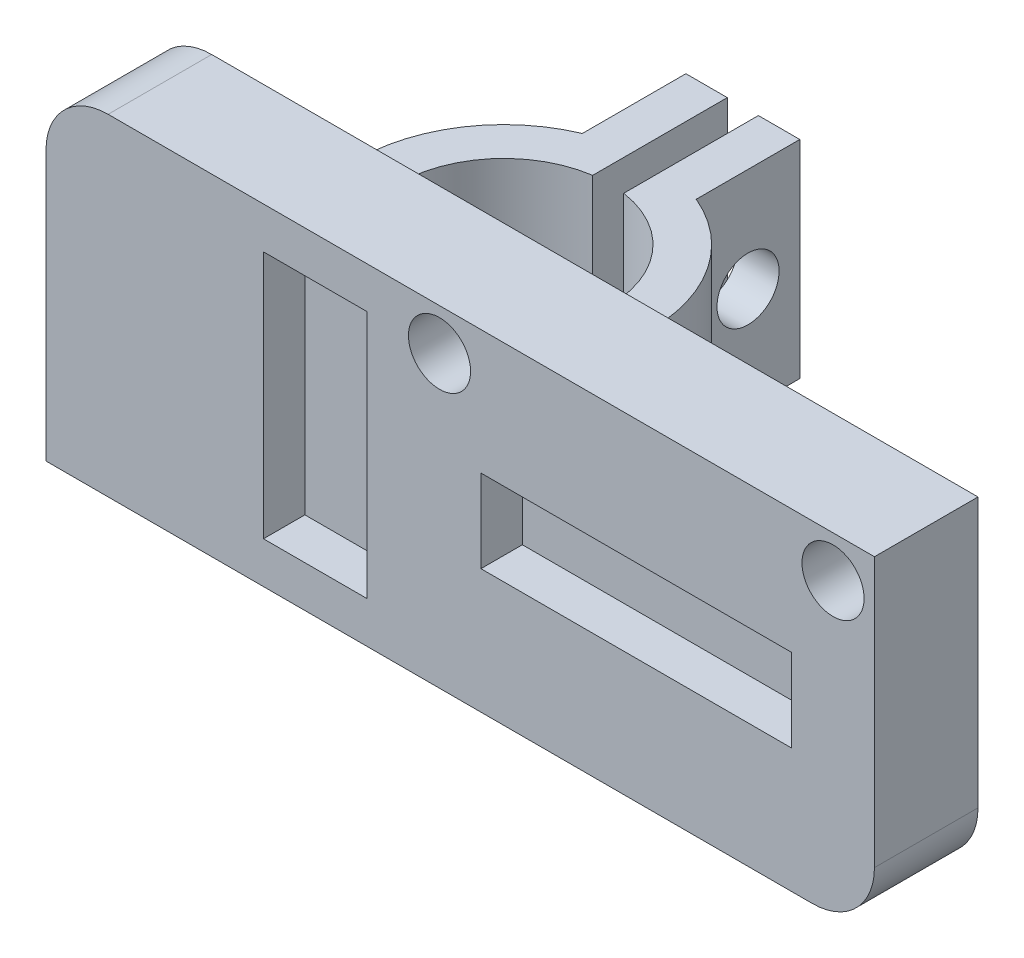
from build123d import *

# Parameters (mm, degrees)
ESBO_O1_R                = 1.5
RESSALTO_EXTRUS_O1_DEPTH = 5
ESBO_O1_3_W              = 5
ESBO_O1_3_H              = 12
ESBO_O1_3_W_2            = 15
ESBO_O1_3_H_2            = 4
CORTE_EXTRUS_O1_DEPTH    = 2
RESSALTO_EXTRUS_O2_DEPTH = 10
ESBO_O3_R                = 1.5
CORTE_EXTRUS_O2_DEPTH    = 10


with BuildPart() as part:
    # Esboço1 → Ressalto-extrusão1 (new body)
    with BuildSketch(Plane.XY):
        with BuildLine():
            Line((40, 16), (3, 16))
            ThreePointArc((3, 16), (0.878679656, 15.121320344), (0, 13))
            Line((0, 13), (0, 0))
            Line((0, 0), (37, 0))
            ThreePointArc((37, 0), (39.121320344, 0.878679656), (40, 3))
            Line((40, 3), (40, 16))
        make_face()
        with Locations((19, 14)):
            Circle(ESBO_O1_R, mode=Mode.SUBTRACT)
        with Locations((38, 14)):
            Circle(ESBO_O1_R, mode=Mode.SUBTRACT)
    extrude(amount=-RESSALTO_EXTRUS_O1_DEPTH)

    # Esboço1<3> → Corte-extrusão1 (cut)
    with BuildSketch(Plane.XY):
        with Locations((13, 8)):
            Rectangle(ESBO_O1_3_W, ESBO_O1_3_H)
        with Locations((28.5, 8)):
            Rectangle(ESBO_O1_3_W_2, ESBO_O1_3_H_2)
    extrude(amount=-CORTE_EXTRUS_O1_DEPTH, mode=Mode.SUBTRACT)

    # Esboço2 → Ressalto-extrusão2 (add)
    with BuildSketch(Plane.XZ):
        with BuildLine():
            Line((19.1, -5), (12.000000019, -5))
            ThreePointArc((12.000000019, -5), (17.086118989, -9.723976561), (12.75, -15.144551516))
            Line((12.75, -15.144551516), (12.75, -21.64580018))
            Line((12.75, -21.64580018), (14.75, -21.64580018))
            Line((14.75, -21.64580018), (14.75, -16.64580018))
            ThreePointArc((14.75, -16.64580018), (17.913332394, -14.029694645), (19.1, -10.1))
            Line((19.1, -10.1), (19.1, -5))
        make_face()
        with BuildLine():
            Line((12.000000019, -5), (4.9, -5))
            Line((4.9, -5), (4.9, -10.1))
            ThreePointArc((4.9, -10.1), (6.086667606, -14.029694645), (9.25, -16.64580018))
            Line((9.25, -16.64580018), (9.25, -21.64580018))
            Line((9.25, -21.64580018), (11.25, -21.64580018))
            Line((11.25, -21.64580018), (11.25, -15.144551516))
            ThreePointArc((11.25, -15.144551516), (6.913881012, -9.723976542), (12.000000019, -5))
        make_face()
    extrude(amount=-RESSALTO_EXTRUS_O2_DEPTH)

    # Esboço3 → Corte-extrusão2 (cut)
    with BuildSketch(Plane(origin=(14.75, 0, 0), x_dir=(0, 0, -1), z_dir=(1, 0, 0))):
        with Locations((19.14580018, 5)):
            Circle(ESBO_O3_R)
    extrude(amount=-CORTE_EXTRUS_O2_DEPTH, mode=Mode.SUBTRACT)


solid = part.part
